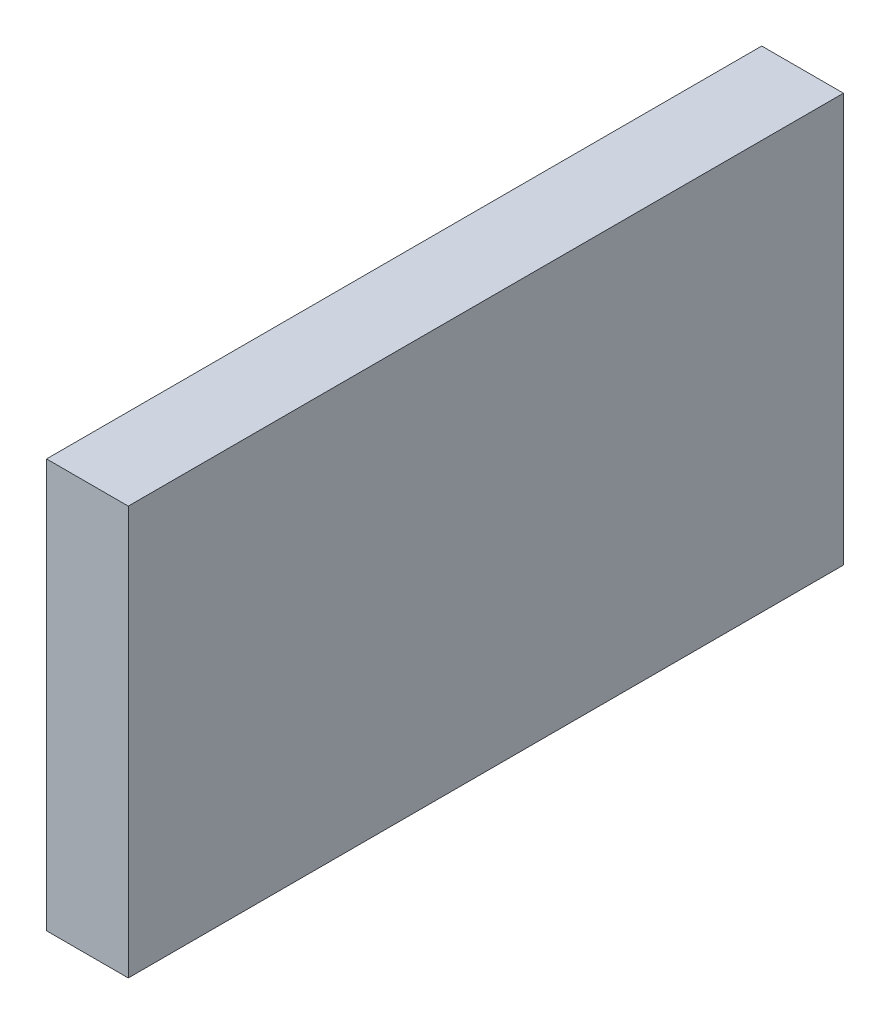
from build123d import *

# Parameters (mm, degrees)
SKETCH2_W           = 35
SKETCH2_H           = 20
BOSS_EXTRUDE1_DEPTH = 4


with BuildPart() as part:
    # Sketch2 → Boss-Extrude1 (new body)
    with BuildSketch(Plane(origin=(0, 0, 0), x_dir=(0, 0, -1), z_dir=(1, 0, 0))):
        with Locations((17.5, 10)):
            Rectangle(SKETCH2_W, SKETCH2_H)
    extrude(amount=BOSS_EXTRUDE1_DEPTH)


solid = part.part
